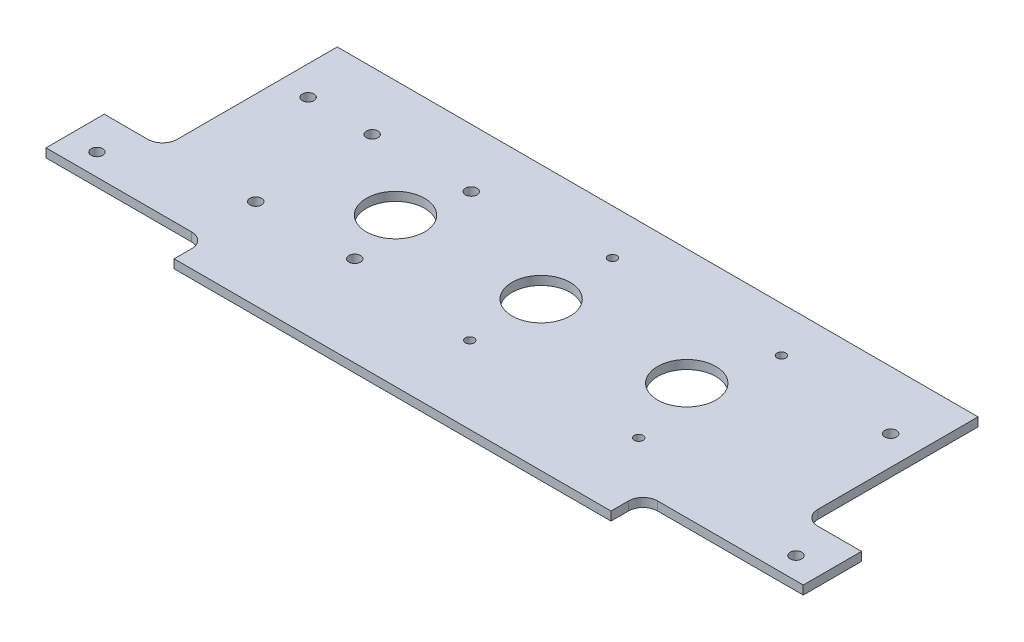
from build123d import *

# Parameters (mm, degrees)
SKETCH1_W           = 220
SKETCH1_H           = 80
BOSS_EXTRUDE1_DEPTH = 3
SKETCH2_W           = 20
SKETCH2_H           = 20
SKETCH2_R           = 2
BOSS_EXTRUDE2_DEPTH = 3
FILLET1_R           = 5
SKETCH3_R           = 2
CUT_EXTRUDE1_DEPTH  = 3
SKETCH4_R           = 1.5
CUT_EXTRUDE2_DEPTH  = 3
SKETCH5_W           = 150
SKETCH5_H           = 22
BOSS_EXTRUDE3_DEPTH = 3
FILLET2_R           = 5
SKETCH6_R           = 10
CUT_EXTRUDE3_DEPTH  = 3
SKETCH7_R           = 2
CUT_EXTRUDE4_DEPTH  = 3


with BuildPart() as part:
    # Sketch1 → Boss-Extrude1 (new body)
    with BuildSketch(Plane(origin=(0, 0, 0), x_dir=(1, 0, 0), z_dir=(0, 1, 0))):
        Rectangle(SKETCH1_W, SKETCH1_H)
    extrude(amount=BOSS_EXTRUDE1_DEPTH)

    # Sketch2 → Boss-Extrude2 (add)
    with BuildSketch(Plane(origin=(0, 3, 0), x_dir=(1, 0, 0), z_dir=(0, 1, 0))):
        with Locations((-120, -30)):
            Rectangle(SKETCH2_W, SKETCH2_H)
        with Locations((-120, -32.5)):
            Circle(SKETCH2_R, mode=Mode.SUBTRACT)
    boss_extrude2 = extrude(amount=-BOSS_EXTRUDE2_DEPTH)

    # Mirror1: Boss-Extrude2 across plane
    add(boss_extrude2.mirror(Plane(origin=(0, 0, 0), x_dir=(0, 0, 1), z_dir=(1, 0, 0))))

    # Fillet1
    fillet1_edges = [part.edges().sort_by_distance(p)[0] for p in [
        (-110, 1.5, 20),
        (110, 1.5, 20),
    ]]
    fillet(fillet1_edges, radius=FILLET1_R)

    # Sketch3 → Cut-Extrude1 (cut)
    with BuildSketch(Plane(origin=(0, 3, 0), x_dir=(1, 0, 0), z_dir=(0, 1, 0))):
        with Locations((-100, 20)):
            Circle(SKETCH3_R)
        with Locations((100, 20)):
            Circle(SKETCH3_R)
    extrude(amount=-CUT_EXTRUDE1_DEPTH, mode=Mode.SUBTRACT)

    # Sketch4 → Cut-Extrude2 (cut)
    with BuildSketch(Plane(origin=(0, 3, 0), x_dir=(1, 0, 0), z_dir=(0, 1, 0))):
        with Locations((0, 24.5)):
            Circle(SKETCH4_R)
        with Locations((58, 24.5)):
            Circle(SKETCH4_R)
        with Locations((58, -24.5)):
            Circle(SKETCH4_R)
        with Locations((0, -24.5)):
            Circle(SKETCH4_R)
    extrude(amount=-CUT_EXTRUDE2_DEPTH, mode=Mode.SUBTRACT)

    # Sketch5 → Boss-Extrude3 (add)
    with BuildSketch(Plane(origin=(0, 3, 0), x_dir=(1, 0, 0), z_dir=(0, 1, 0))):
        with Locations((0, -40)):
            Rectangle(SKETCH5_W, SKETCH5_H)
    extrude(amount=-BOSS_EXTRUDE3_DEPTH)

    # Fillet2
    fillet2_edges = [part.edges().sort_by_distance(p)[0] for p in [
        (-75, 1.5, 40),
        (75, 1.5, 40),
    ]]
    fillet(fillet2_edges, radius=FILLET2_R)

    # Sketch6 → Cut-Extrude3 (cut)
    with BuildSketch(Plane(origin=(0, 3, 0), x_dir=(1, 0, 0), z_dir=(0, 1, 0))):
        with Locations((-50, 0)):
            Circle(SKETCH6_R)
        Circle(SKETCH6_R)
        with Locations((50, 0)):
            Circle(SKETCH6_R)
    extrude(amount=-CUT_EXTRUDE3_DEPTH, mode=Mode.SUBTRACT)

    # Sketch7 → Cut-Extrude4 (cut)
    with BuildSketch(Plane(origin=(0, 3, 0), x_dir=(1, 0, 0), z_dir=(0, 1, 0))):
        with Locations((-78, 20)):
            Circle(SKETCH7_R)
        with Locations((-44, 20)):
            Circle(SKETCH7_R)
        with Locations((-44, -20)):
            Circle(SKETCH7_R)
        with Locations((-78, -20)):
            Circle(SKETCH7_R)
    extrude(amount=-CUT_EXTRUDE4_DEPTH, mode=Mode.SUBTRACT)


solid = part.part
